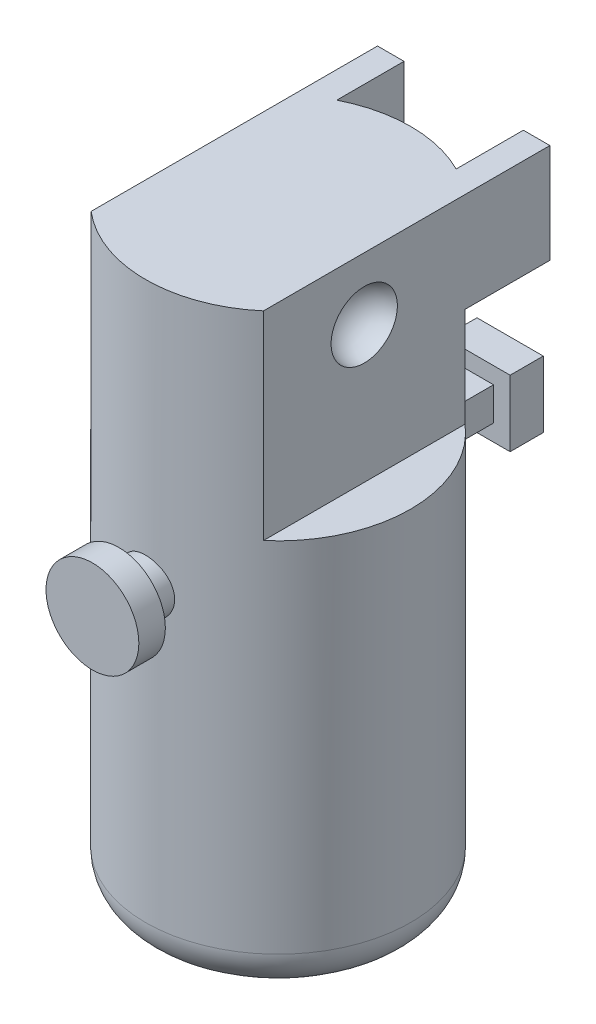
from build123d import *
from build123d.topology import SkipClean

# Parameters (mm, degrees)
SKETCH1_R                            = 10
BOSS_EXTRUDE2_DEPTH                  = 45
SKETCH4_OUTSIDE_W                    = 32.63
SKETCH4_OUTSIDE_H                    = 32.63
SKETCH4_OUTSIDE_W_2                  = 13
SKETCH4_OUTSIDE_H_2                  = 20
CUT_EXTRUDE2_DEPTH                   = 15
FILLET2_R                            = 3
BOSS_EXTRUDE3_REACH                  = 52.249
BOSS_EXTRUDE3_END_RADIUS             = 10
SKETCH7_W                            = 2.5
SKETCH7_H                            = 2.5
BOSS_EXTRUDE3_DIRECTION_2_DEPTH      = 5
SKETCH8_W                            = 5
SKETCH8_H                            = 5
BOSS_EXTRUDE4_DEPTH                  = 2.5
SKETCH9_R                            = 2
BOSS_EXTRUDE6_DEPTH                  = 2
BOSS_EXTRUDE6_DIRECTION_2_REACH      = 55.677
BOSS_EXTRUDE6_DIRECTION_2_END_RADIUS = 10
SKETCH10_R                           = 3.5
BOSS_EXTRUDE7_DEPTH                  = 2
SKETCH11_W                           = 6.400657923
SKETCH11_H                           = 7.5
BOSS_EXTRUDE8_DEPTH                  = 2


with BuildPart() as part:
    # Sketch1 → Boss-Extrude2 (new body)
    with BuildSketch(Plane(origin=(0, 0, 0), x_dir=(1, 0, 0), z_dir=(0, 1, 0))):
        Circle(SKETCH1_R)
    extrude(amount=BOSS_EXTRUDE2_DEPTH)

    # Sketch4 outside → Cut-Extrude2 (cut)
    with BuildSketch(Plane(origin=(0, 45, 0), x_dir=(1, 0, 0), z_dir=(0, 1, 0))):
        Rectangle(SKETCH4_OUTSIDE_W, SKETCH4_OUTSIDE_H)
        Rectangle(SKETCH4_OUTSIDE_W_2, SKETCH4_OUTSIDE_H_2, mode=Mode.SUBTRACT)
    extrude(amount=-CUT_EXTRUDE2_DEPTH, mode=Mode.SUBTRACT)

    # Sketch5 → Cut-Revolve1 (revolve, cut)
    with BuildSketch(Plane.ZY.offset(6.5)):
        with BuildLine():
            Line((0, 42.792409201), (0, 37.792409201))
            ThreePointArc((0, 37.792409201), (-2.5, 40.292409201), (0, 42.792409201))
        make_face()
    cut_revolve1 = revolve(axis=Axis((-6.5, 42.792409201, 0), (0, -1, 0)), mode=Mode.SUBTRACT)

    # Mirror2: Cut-Revolve1 across plane
    add(cut_revolve1.mirror(Plane(origin=(0, 0, 0), x_dir=(0, 0, 1), z_dir=(1, 0, 0))), mode=Mode.SUBTRACT)

    # Fillet2
    fillet2_edges = [part.edges().sort_by_distance(p)[0] for p in [
        (-10, 0, 0),
    ]]
    fillet(fillet2_edges, radius=FILLET2_R)

    # Boss-Extrude3: up to this cylinder (the profile starts outside it)
    boss_extrude3_end = Plane(origin=(0, 25, 0), z_dir=(0, -1, 0)) * Cylinder(BOSS_EXTRUDE3_END_RADIUS, 125.498, mode=Mode.PRIVATE)
    # Sketch7 → Boss-Extrude3 (add, up to the surface)
    with BuildSketch(Plane.XY.offset(-10), mode=Mode.PRIVATE) as boss_extrude3_sk1:
        with Locations((0, 25)):
            Rectangle(SKETCH7_W, SKETCH7_H)
    boss_extrude3_tool1 = extrude(boss_extrude3_sk1.sketch, amount=BOSS_EXTRUDE3_REACH, mode=Mode.PRIVATE) - boss_extrude3_end
    add(boss_extrude3_tool1.solids().sort_by_distance((0, 25, -10))[0])
    add(boss_extrude3_tool1.solids().sort_by_distance((0, 25, -10))[1])

    # Sketch7 → Boss-Extrude3 direction 2 (add)
    with BuildSketch(Plane.XY.offset(-10)):
        with Locations((0, 25)):
            Rectangle(SKETCH7_W, SKETCH7_H)
    extrude(amount=-BOSS_EXTRUDE3_DIRECTION_2_DEPTH)

    # Sketch8 → Boss-Extrude4 (add)
    with BuildSketch(Plane(origin=(0, 0, -15), x_dir=(-1, 0, 0), z_dir=(0, 0, -1))):
        with Locations((0, 25)):
            Rectangle(SKETCH8_W, SKETCH8_H)
    extrude(amount=BOSS_EXTRUDE4_DEPTH)

    # Sketch9 → Boss-Extrude6 (add)
    with BuildSketch(Plane.XY.offset(10)):
        with Locations((0, 25)):
            Circle(SKETCH9_R)
    extrude(amount=BOSS_EXTRUDE6_DEPTH)

    # Boss-Extrude6 direction 2: up to this cylinder (the profile starts outside it)
    with SkipClean():  # the faces are left unmerged after this step: merging them gives an invalid solid
        boss_extrude6_direction_2_end = Plane(origin=(0, 25, 0), z_dir=(0, -1, 0)) * Cylinder(BOSS_EXTRUDE6_DIRECTION_2_END_RADIUS, 132.354, mode=Mode.PRIVATE)
        # Sketch9 → Boss-Extrude6 direction 2 (add, up to the surface)
        with BuildSketch(Plane.XY.offset(10), mode=Mode.PRIVATE) as boss_extrude6_direction_2_sk1:
            with Locations((0, 25)):
                Circle(SKETCH9_R)
        boss_extrude6_direction_2_tool1 = extrude(boss_extrude6_direction_2_sk1.sketch, amount=-BOSS_EXTRUDE6_DIRECTION_2_REACH, mode=Mode.PRIVATE) - boss_extrude6_direction_2_end
        add(boss_extrude6_direction_2_tool1.solids().sort_by_distance((0, 25, 10))[0])
        add(boss_extrude6_direction_2_tool1.solids().sort_by_distance((0, 25, 10))[1])

    # Sketch10 → Boss-Extrude7 (add)
    with SkipClean():  # the faces are left unmerged after this step: merging them gives an invalid solid
        with BuildSketch(Plane.XY.offset(12)):
            with Locations((0, 24.995165492)):
                Circle(SKETCH10_R)
        extrude(amount=BOSS_EXTRUDE7_DEPTH)

    # Sketch11 → Boss-Extrude8 (add)
    with SkipClean():  # the faces are left unmerged after this step: merging them gives an invalid solid
        with BuildSketch(Plane(origin=(6.5, 0, 0), x_dir=(0, 0, -1), z_dir=(1, 0, 0))):
            with Locations((10.799671038, 41.25)):
                Rectangle(SKETCH11_W, SKETCH11_H)
        boss_extrude8 = extrude(amount=-BOSS_EXTRUDE8_DEPTH)

    # Mirror3: Boss-Extrude8 across plane
    with SkipClean():  # the faces are left unmerged after this step: merging them gives an invalid solid
        add(boss_extrude8.mirror(Plane(origin=(0, 0, 0), x_dir=(0, 0, 1), z_dir=(1, 0, 0))))


solid = part.part
